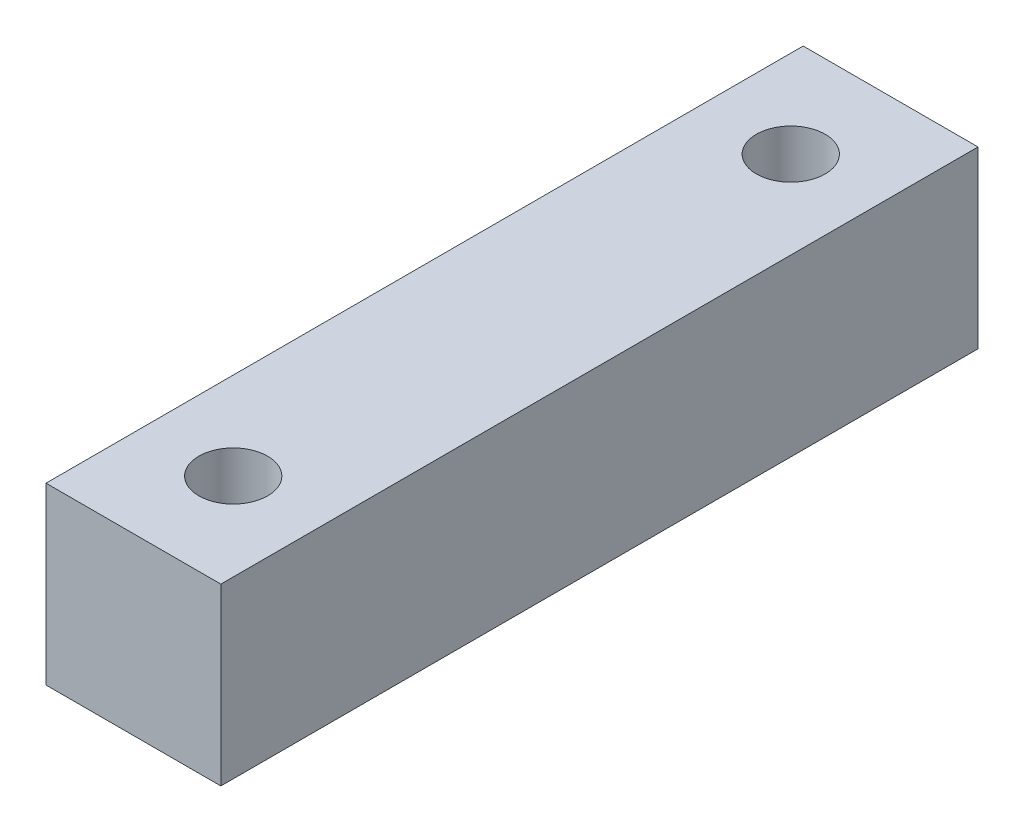
from build123d import *

# Parameters (mm, degrees)
SKETCH1_W           = 12.7
SKETCH1_H           = 55
SKETCH1_R           = 2.5
BOSS_EXTRUDE1_DEPTH = 12.7


with BuildPart() as part:
    # Sketch1 → Boss-Extrude1 (new body)
    with BuildSketch(Plane(origin=(0, 0, 0), x_dir=(1, 0, 0), z_dir=(0, 1, 0))):
        with Locations((6.35, 27.5)):
            Rectangle(SKETCH1_W, SKETCH1_H)
        with Locations((6.35, 7.25)):
            Circle(SKETCH1_R, mode=Mode.SUBTRACT)
        with Locations((6.35, 47.75)):
            Circle(SKETCH1_R, mode=Mode.SUBTRACT)
    extrude(amount=BOSS_EXTRUDE1_DEPTH)


solid = part.part
